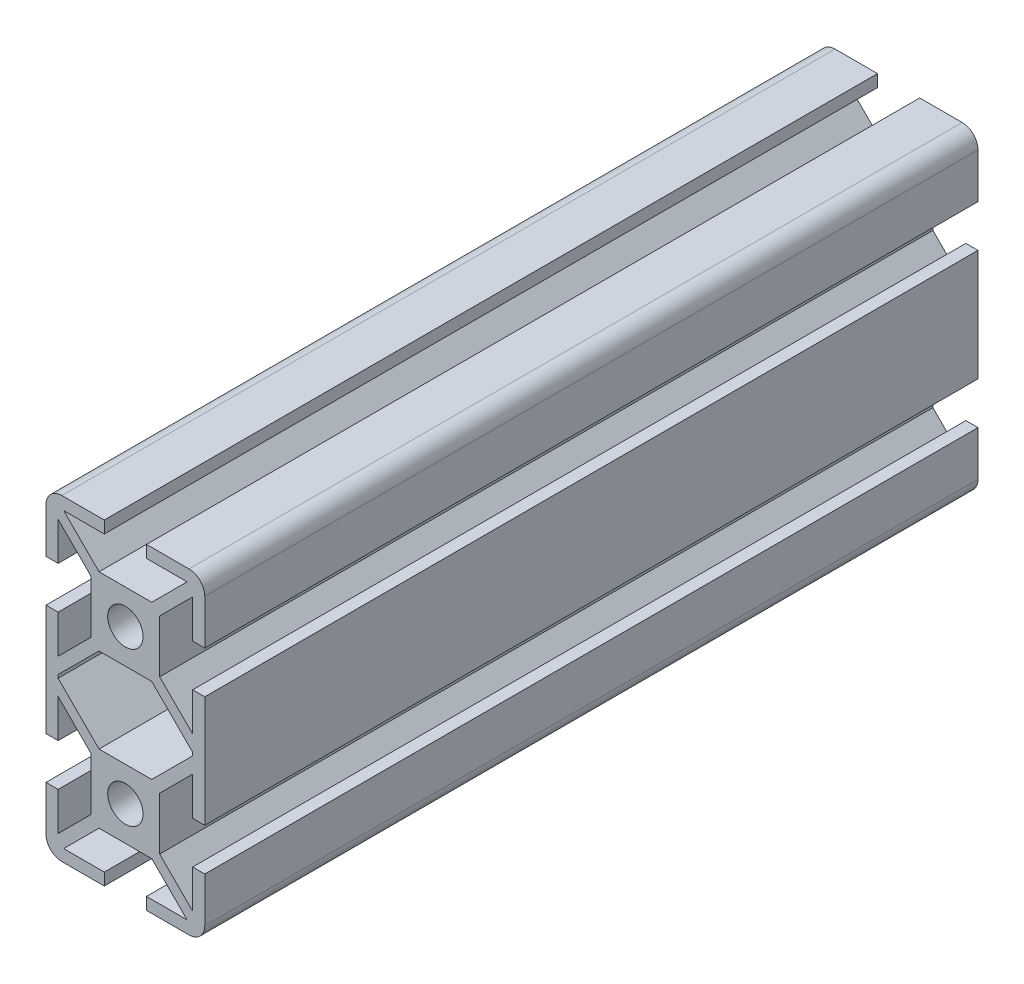
from build123d import *

# Parameters (mm, degrees)
CROQUIS1_R              = 3.35
SALIENTE_EXTRUIR1_DEPTH = 146.6


with BuildPart() as part:
    # Croquis1 → Saliente-Extruir1 (new body)
    with BuildSketch(Plane.XY):
        with BuildLine():
            Line((-12.05, -30.05), (-4, -30.05))
            Line((-4, -30.05), (-4, -27.75))
            Line((-4, -27.75), (-11.7, -27.75))
            Line((-11.7, -27.75), (-5, -21.05))
            Line((-5, -21.05), (5, -21.05))
            Line((5, -21.05), (11.7, -27.75))
            Line((11.7, -27.75), (4, -27.75))
            Line((4, -27.75), (4, -30.05))
            Line((4, -30.05), (12.05, -30.05))
            ThreePointArc((12.05, -30.05), (14.171320344, -29.171320344), (15.05, -27.05))
            Line((15.05, -27.05), (15.05, -18.55))
            Line((15.05, -18.55), (12.75, -18.55))
            Line((12.75, -18.55), (12.75, -25.8))
            Line((12.75, -25.8), (6.5, -19.55))
            Line((6.5, -19.55), (6.5, -9.55))
            Line((6.5, -9.55), (12.75, -3.3))
            Line((12.75, -3.3), (12.75, -10.55))
            Line((12.75, -10.55), (15.05, -10.55))
            Line((15.05, -10.55), (15.05, 10.55))
            Line((15.05, 10.55), (12.75, 10.55))
            Line((12.75, 10.55), (12.75, 3.3))
            Line((12.75, 3.3), (6.5, 9.55))
            Line((6.5, 9.55), (6.5, 19.55))
            Line((6.5, 19.55), (12.75, 25.8))
            Line((12.75, 25.8), (12.75, 18.55))
            Line((12.75, 18.55), (15.05, 18.55))
            Line((15.05, 18.55), (15.05, 27.05))
            ThreePointArc((15.05, 27.05), (14.171320344, 29.171320344), (12.05, 30.05))
            Line((12.05, 30.05), (4, 30.05))
            Line((4, 30.05), (4, 27.75))
            Line((4, 27.75), (11.7, 27.75))
            Line((11.7, 27.75), (5, 21.05))
            Line((5, 21.05), (-5, 21.05))
            Line((-5, 21.05), (-11.7, 27.75))
            Line((-11.7, 27.75), (-4, 27.75))
            Line((-4, 27.75), (-4, 30.05))
            Line((-4, 30.05), (-12.05, 30.05))
            ThreePointArc((-12.05, 30.05), (-14.171320344, 29.171320344), (-15.05, 27.05))
            Line((-15.05, 27.05), (-15.05, 18.55))
            Line((-15.05, 18.55), (-12.75, 18.55))
            Line((-12.75, 18.55), (-12.75, 25.8))
            Line((-12.75, 25.8), (-6.5, 19.55))
            Line((-6.5, 19.55), (-6.5, 9.55))
            Line((-6.5, 9.55), (-12.75, 3.3))
            Line((-12.75, 3.3), (-12.75, 10.55))
            Line((-12.75, 10.55), (-15.05, 10.55))
            Line((-15.05, 10.55), (-15.05, -10.55))
            Line((-15.05, -10.55), (-12.75, -10.55))
            Line((-12.75, -10.55), (-12.75, -3.3))
            Line((-12.75, -3.3), (-6.5, -9.55))
            Line((-6.5, -9.55), (-6.5, -19.55))
            Line((-6.5, -19.55), (-12.75, -25.8))
            Line((-12.75, -25.8), (-12.75, -18.55))
            Line((-12.75, -18.55), (-15.05, -18.55))
            Line((-15.05, -18.55), (-15.05, -27.05))
            ThreePointArc((-15.05, -27.05), (-14.171320344, -29.171320344), (-12.05, -30.05))
        make_face()
        with Locations((0, 14.55)):
            Circle(CROQUIS1_R, mode=Mode.SUBTRACT)
        with Locations((0, -14.55)):
            Circle(CROQUIS1_R, mode=Mode.SUBTRACT)
        Polygon((-5, 8.05), (5, 8.05), (11.7, 1.35), (12.75, 0.3), (12.75, -0.3), (11.7, -1.35), (5, -8.05), (-5, -8.05), (-11.7, -1.35), (-12.75, -0.3), (-12.75, 0.3), (-11.7, 1.35), align=None, mode=Mode.SUBTRACT)
    extrude(amount=SALIENTE_EXTRUIR1_DEPTH)


solid = part.part
